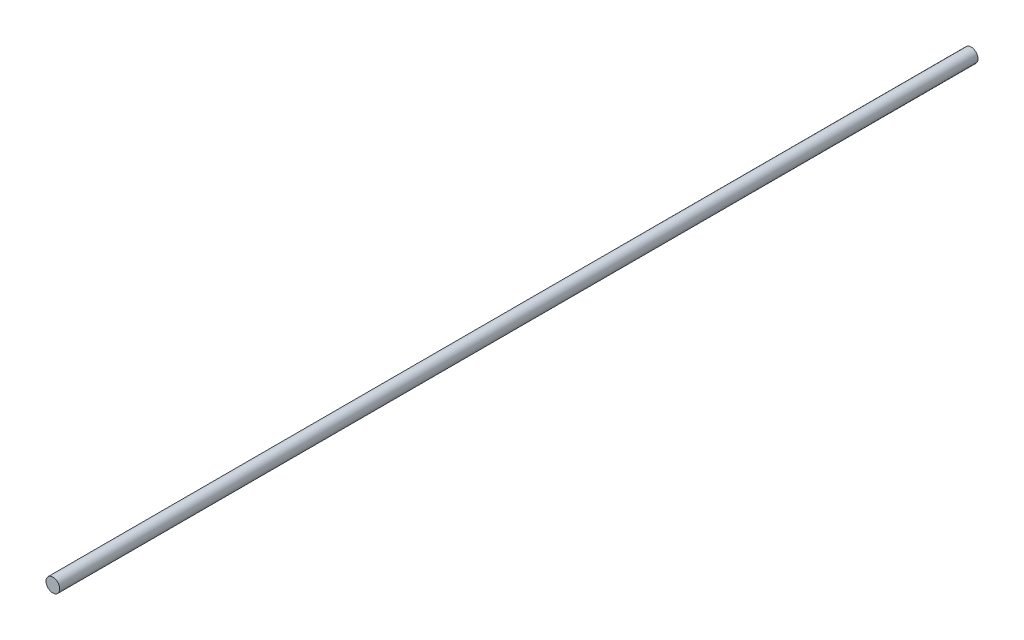
from build123d import *

# Parameters (mm, degrees)
SKETCH1_R           = 3
BOSS_EXTRUDE1_DEPTH = 200


with BuildPart() as part:
    # Sketch1 → Boss-Extrude1 (new body, symmetric)
    with BuildSketch(Plane.XY):
        Circle(SKETCH1_R)
    extrude(amount=BOSS_EXTRUDE1_DEPTH, both=True)


solid = part.part
